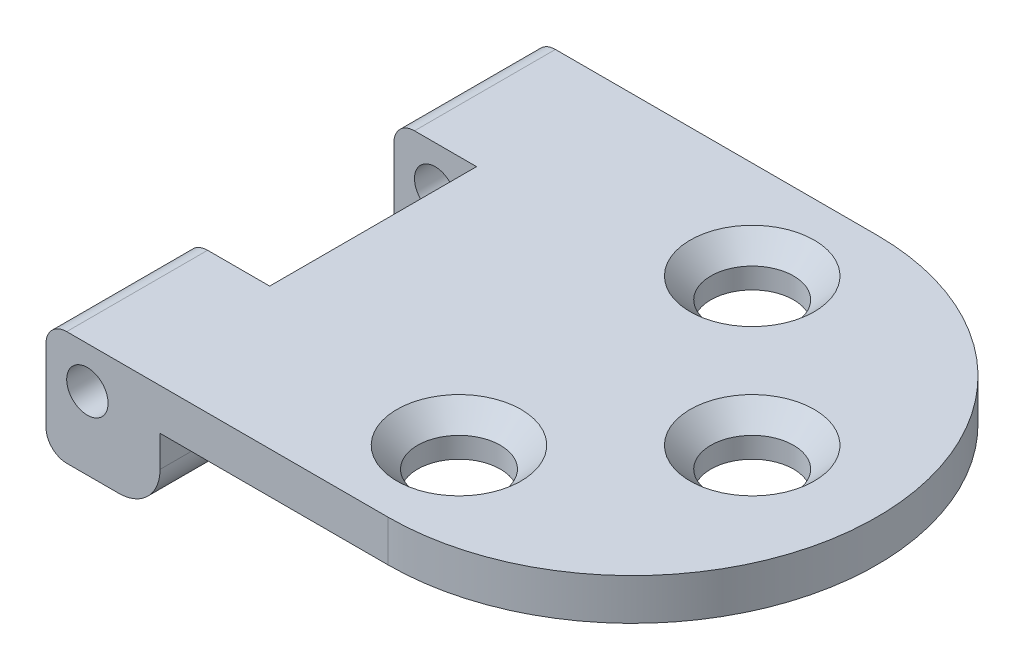
from build123d import *

# Parameters (mm, degrees)
BOSS_EXTRUDE1_DEPTH = 7
SKETCH2_W           = 29.216076644
SKETCH2_H           = 30
CUT_EXTRUDE1_DEPTH  = 4.46
FILLET1_R           = 2.54
FILLET2_R           = 1.27
CUT_EXTRUDE2_REACH  = 9
SKETCH3_R           = 2.54
SKETCH3_W           = 5.08
SKETCH3_H           = 12.7
CHAMFER1_SIZE       = 1.27
SKETCH4_R           = 1.27
CUT_EXTRUDE3_DEPTH  = 31


with BuildPart() as part:
    # Sketch1 → Boss-Extrude1 (new body)
    with BuildSketch(Plane(origin=(0, 0, 0), x_dir=(1, 0, 0), z_dir=(0, 1, 0))):
        with BuildLine():
            Line((0, 0), (21.000000028, 0))
            ThreePointArc((21.000000028, 0), (36.000000028, 15), (21.000000028, 30))
            Line((21.000000028, 30), (0, 30))
            Line((0, 30), (0, 0))
        make_face()
    extrude(amount=BOSS_EXTRUDE1_DEPTH)

    # Sketch2 → Cut-Extrude1 (cut)
    with BuildSketch(Plane.XZ):
        with Locations((21.608038322, -15)):
            Rectangle(SKETCH2_W, SKETCH2_H)
    extrude(amount=-CUT_EXTRUDE1_DEPTH, mode=Mode.SUBTRACT)

    # Fillet1
    fillet1_edges = [part.edges().sort_by_distance(p)[0] for p in [
        (7, 0, -15),
    ]]
    fillet(fillet1_edges, radius=FILLET1_R)

    # Fillet2
    fillet2_edges = [part.edges().sort_by_distance(p)[0] for p in [
        (0, 7, -15),
        (0, 0, -15),
    ]]
    fillet(fillet2_edges, radius=FILLET2_R)

    # Sketch3 → Cut-Extrude2 (cut, up to next)
    with BuildSketch(Plane(origin=(0, 7, 0), x_dir=(1, 0, 0), z_dir=(0, 1, 0)), mode=Mode.PRIVATE) as cut_extrude2_sk1:
        with Locations((28.34999918, 15)):
            Circle(SKETCH3_R)
    cut_extrude2_tool1 = extrude(cut_extrude2_sk1.sketch, amount=-CUT_EXTRUDE2_REACH, mode=Mode.PRIVATE) & part.part
    add(cut_extrude2_tool1.solids().sort_by_distance((28.349999, 7, -15))[0], mode=Mode.SUBTRACT)
    # Sketch3 → Cut-Extrude2 (cut, up to next)
    with BuildSketch(Plane(origin=(0, 7, 0), x_dir=(1, 0, 0), z_dir=(0, 1, 0)), mode=Mode.PRIVATE) as cut_extrude2_sk2:
        with Locations((19.3499994, 23.99999978)):
            Circle(SKETCH3_R)
    cut_extrude2_tool2 = extrude(cut_extrude2_sk2.sketch, amount=-CUT_EXTRUDE2_REACH, mode=Mode.PRIVATE) & part.part
    add(cut_extrude2_tool2.solids().sort_by_distance((19.349999, 7, -24))[0], mode=Mode.SUBTRACT)
    # Sketch3 → Cut-Extrude2 (cut, up to next)
    with BuildSketch(Plane(origin=(0, 7, 0), x_dir=(1, 0, 0), z_dir=(0, 1, 0)), mode=Mode.PRIVATE) as cut_extrude2_sk3:
        with Locations((19.3499994, 6.00000022)):
            Circle(SKETCH3_R)
    cut_extrude2_tool3 = extrude(cut_extrude2_sk3.sketch, amount=-CUT_EXTRUDE2_REACH, mode=Mode.PRIVATE) & part.part
    add(cut_extrude2_tool3.solids().sort_by_distance((19.349999, 7, -6))[0], mode=Mode.SUBTRACT)
    # Sketch3 → Cut-Extrude2 (cut, up to next)
    with BuildSketch(Plane(origin=(0, 7, 0), x_dir=(1, 0, 0), z_dir=(0, 1, 0)), mode=Mode.PRIVATE) as cut_extrude2_sk4:
        with Locations((2.54, 15)):
            Rectangle(SKETCH3_W, SKETCH3_H)
    cut_extrude2_tool4 = extrude(cut_extrude2_sk4.sketch, amount=-CUT_EXTRUDE2_REACH, mode=Mode.PRIVATE) & part.part
    add(cut_extrude2_tool4.solids().sort_by_distance((2.54, 7, -15))[0], mode=Mode.SUBTRACT)

    # Chamfer1
    chamfer1_edges = [part.edges().sort_by_distance(p)[0] for p in [
        (25.80999918, 7, -15),
        (16.8099994, 7, -23.99999978),
        (16.8099994, 7, -6.00000022),
    ]]
    chamfer(chamfer1_edges, length=CHAMFER1_SIZE)

    # Sketch4 → Cut-Extrude3 (cut, through all)
    with BuildSketch(Plane.XY):
        with Locations((2.54, 4.46)):
            Circle(SKETCH4_R)
    extrude(amount=-CUT_EXTRUDE3_DEPTH, mode=Mode.SUBTRACT)


solid = part.part
